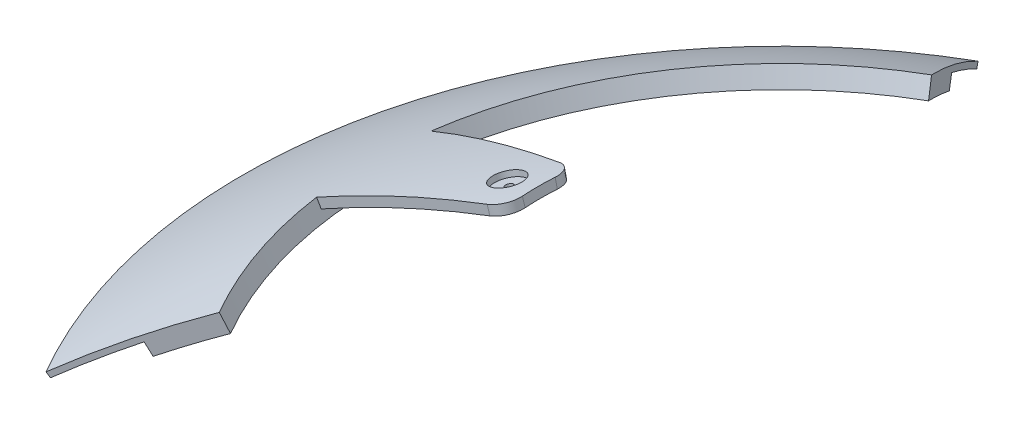
from build123d import *

# Parameters (mm, degrees)
REVOLVE1_ANGLE           = 30
REVOLVE1_OTHER_WAY_ANGLE = 60
REVOLVE2_ANGLE           = 8
REVOLVE2_OTHER_WAY_ANGLE = 8
FILLET1_R                = 5
REVOLVE3_ANGLE           = 7.5
REVOLVE3_OTHER_WAY_ANGLE = 7.5


with BuildPart() as part:
    # Sketch2 → Revolve1 (revolve)
    with BuildSketch(Plane.XY):
        with BuildLine():
            Line((-124.25, 215.20731284), (-122.5, 212.176223927))
            ThreePointArc((-122.5, 212.176223927), (-115.020532883, 216.32216025), (-107.400930963, 220.204541343))
            Line((-107.400930963, 220.204541343), (-109.592786697, 224.698511575))
            ThreePointArc((-109.592786697, 224.698511575), (-126.88459074, 215.40729011), (-143.394109088, 204.788011072))
            Line((-143.394109088, 204.788011072), (-142.533744433, 203.559283006))
            ThreePointArc((-142.533744433, 203.559283006), (-133.518952674, 209.582774285), (-124.25, 215.20731284))
        make_face()
    revolve(axis=Axis((0, 0, 0), (0, 1, 0)), revolution_arc=REVOLVE1_ANGLE)

    # Sketch2 → Revolve1 other way (revolve)
    with BuildSketch(Plane.XY):
        with BuildLine():
            Line((-124.25, 215.20731284), (-122.5, 212.176223927))
            ThreePointArc((-122.5, 212.176223927), (-115.020532883, 216.32216025), (-107.400930963, 220.204541343))
            Line((-107.400930963, 220.204541343), (-109.592786697, 224.698511575))
            ThreePointArc((-109.592786697, 224.698511575), (-126.88459074, 215.40729011), (-143.394109088, 204.788011072))
            Line((-143.394109088, 204.788011072), (-142.533744433, 203.559283006))
            ThreePointArc((-142.533744433, 203.559283006), (-133.518952674, 209.582774285), (-124.25, 215.20731284))
        make_face()
    revolve(axis=Axis((0, 0, 0), (0, -1, 0)), revolution_arc=REVOLVE1_OTHER_WAY_ANGLE)

    # Sketch3 → Revolve2 (revolve)
    with BuildSketch(Plane.XY):
        with BuildLine():
            ThreePointArc((-108.49685883, 222.451526459), (-86.676326862, 231.826366839), (-64.057713663, 239.066642007))
            Line((-64.057713663, 239.066642007), (-64.704761276, 241.481456572))
            ThreePointArc((-64.704761276, 241.481456572), (-87.551845315, 234.168047312), (-109.592786697, 224.698511575))
            Line((-109.592786697, 224.698511575), (-108.49685883, 222.451526459))
        make_face()
    revolve(axis=Axis((0, 0, 0), (0, 1, 0)), revolution_arc=REVOLVE2_ANGLE)

    # Sketch3 → Revolve2 other way (revolve)
    with BuildSketch(Plane.XY):
        with BuildLine():
            ThreePointArc((-108.49685883, 222.451526459), (-86.676326862, 231.826366839), (-64.057713663, 239.066642007))
            Line((-64.057713663, 239.066642007), (-64.704761276, 241.481456572))
            ThreePointArc((-64.704761276, 241.481456572), (-87.551845315, 234.168047312), (-109.592786697, 224.698511575))
            Line((-109.592786697, 224.698511575), (-108.49685883, 222.451526459))
        make_face()
    revolve(axis=Axis((0, 0, 0), (0, -1, 0)), revolution_arc=REVOLVE2_OTHER_WAY_ANGLE)

    # Fillet1
    fillet1_edges = [part.edges().sort_by_distance(p)[0] for p in [
        (-63.754683692, 240.274049289, -8.960136462),
        (-63.754683692, 240.274049289, 8.960136462),
    ]]
    fillet(fillet1_edges, radius=FILLET1_R)

    # Sketch4 → Cut-Revolve1 (revolve, cut)
    with BuildSketch(Plane.XY):
        Polygon((-75.028736809, 245.948635315), (-72.508257021, 237.68635355), (-71.551772701, 237.97813728), (-74.110273038, 246.365052654), align=None)
        Polygon((-74.110273038, 246.365052654), (-71.551772701, 237.97813728), (-68.682319741, 238.853488471), (-71.354881726, 247.614304673), align=None)
        with BuildLine():
            Line((-72.508257021, 237.68635355), (-58.356746094, 191.296864024))
            ThreePointArc((-58.356746094, 191.296864024), (-57.878320073, 191.442158538), (-57.39953231, 191.586256529))
            Line((-57.39953231, 191.586256529), (-71.551772701, 237.97813728))
            Line((-71.551772701, 237.97813728), (-72.508257021, 237.68635355))
        make_face()
    revolve(axis=Axis((0, 0, 0), (-0.2917837304684816, 0.9564843201192044, 0)), mode=Mode.SUBTRACT)

    # Sketch7 → Revolve3 (revolve)
    with BuildSketch(Plane.XY):
        with BuildLine():
            ThreePointArc((-133.400699518, 205.497575091), (-130.717474001, 207.214724358), (-128.012148355, 208.896840267))
            Line((-128.012148355, 208.896840267), (-129.057145485, 210.602120595))
            ThreePointArc((-129.057145485, 210.602120595), (-130.890058266, 209.467879751), (-132.713003262, 208.317687116))
            Line((-132.713003262, 208.317687116), (-133.518952674, 209.582774285))
            ThreePointArc((-133.518952674, 209.582774285), (-134.41391709, 209.009925345), (-135.306423797, 208.433254735))
            Line((-135.306423797, 208.433254735), (-133.400699518, 205.497575091))
        make_face()
    revolve(axis=Axis((0, 0, 0), (0, 1, 0)), revolution_arc=REVOLVE3_ANGLE)

    # Sketch7 → Revolve3 other way (revolve)
    with BuildSketch(Plane.XY):
        with BuildLine():
            ThreePointArc((-133.400699518, 205.497575091), (-130.717474001, 207.214724358), (-128.012148355, 208.896840267))
            Line((-128.012148355, 208.896840267), (-129.057145485, 210.602120595))
            ThreePointArc((-129.057145485, 210.602120595), (-130.890058266, 209.467879751), (-132.713003262, 208.317687116))
            Line((-132.713003262, 208.317687116), (-133.518952674, 209.582774285))
            ThreePointArc((-133.518952674, 209.582774285), (-134.41391709, 209.009925345), (-135.306423797, 208.433254735))
            Line((-135.306423797, 208.433254735), (-133.400699518, 205.497575091))
        make_face()
    revolve(axis=Axis((0, 0, 0), (0, -1, 0)), revolution_arc=REVOLVE3_OTHER_WAY_ANGLE)


solid = part.part
